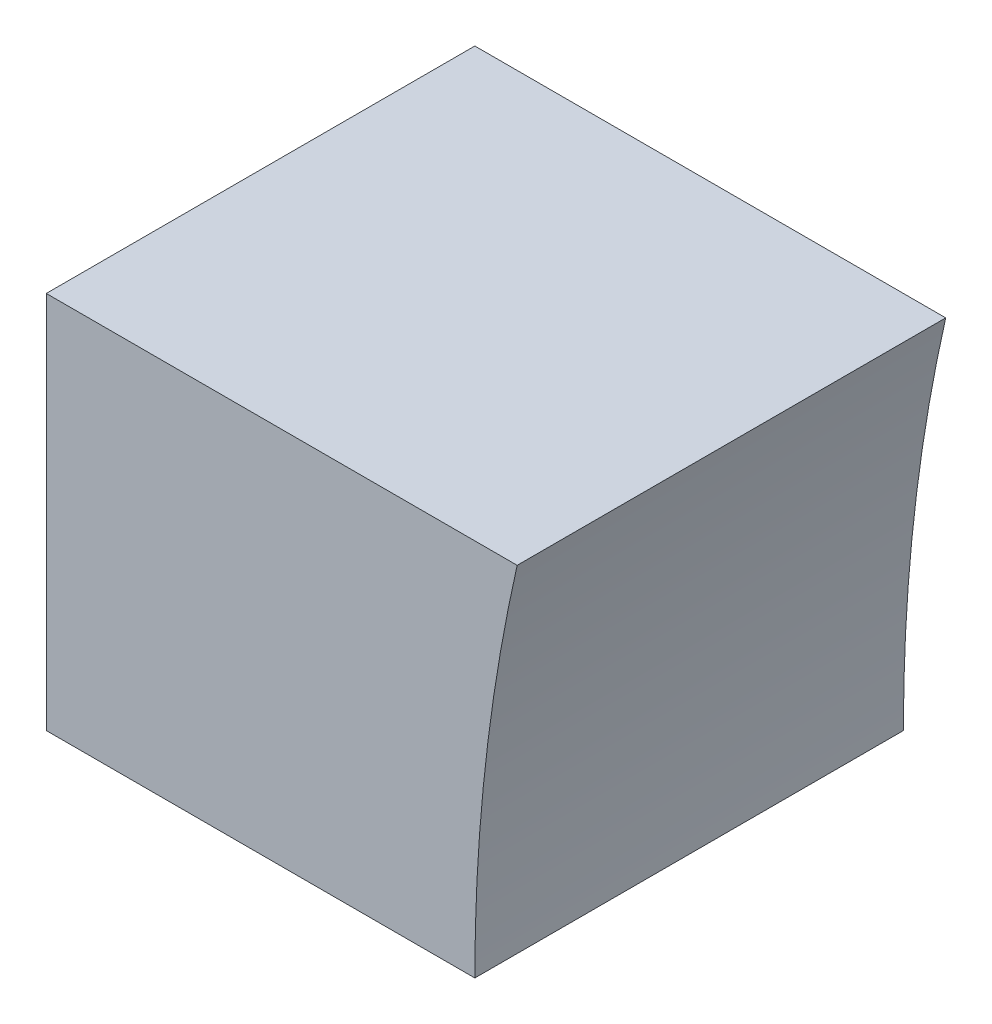
from build123d import *

# Parameters (mm, degrees)
EXTRUDE_1_DEPTH = 480
SCALE_1_SCALE   = 1.3


with BuildPart() as part:
    # 草图1 → 凸台-拉伸1 (new body)
    with BuildSketch(Plane.XY):
        with BuildLine():
            Line((-8640, 3840), (-8160, 3840))
            ThreePointArc((-8160, 3840), (-8148.112750133, 4053.320727495), (-8112.598195022, 4264))
            Line((-8112.598195022, 4264), (-8592.598195022, 4264))
            Line((-8592.598195022, 4264), (-8640, 4264))
            Line((-8640, 4264), (-8640, 3840))
        make_face()
    extrude(amount=EXTRUDE_1_DEPTH)


with BuildPart() as part_1:
    # 缩放比例1: scaled about (0, 0, 0)
    add(part.part.scale(SCALE_1_SCALE))


solid = part_1.part
